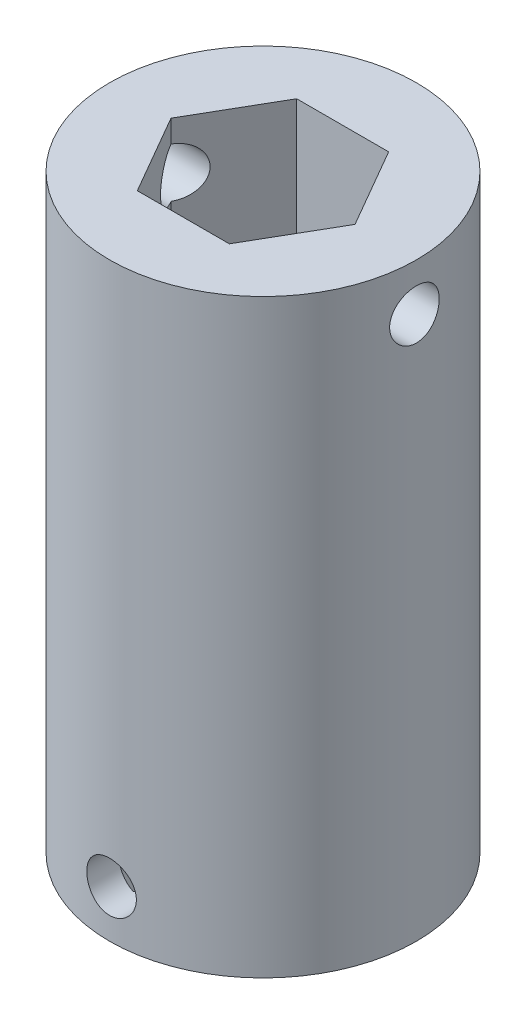
from build123d import *

# Parameters (mm, degrees)
SKETCH1_R               = 13
BOSS_EXTRUDE1_DEPTH     = 30
SKETCH2_R               = 13
BOSS_EXTRUDE2_DEPTH     = 20
CUT_EXTRUDE1_DEPTH      = 23
SKETCH4_R               = 2.1
CUT_EXTRUDE2_DEPTH      = 14
CUT_EXTRUDE2_DEPTH_BACK = 14
SKETCH5_R               = 2.1
CUT_EXTRUDE3_DEPTH      = 14.0000001
CUT_EXTRUDE3_DEPTH_BACK = 14.0000001


with BuildPart() as part:
    # Sketch1 → Boss-Extrude1 (new body)
    with BuildSketch(Plane(origin=(0, 0, 0), x_dir=(1, 0, 0), z_dir=(0, 1, 0))):
        Circle(SKETCH1_R)
        Polygon((7.794228634, 0), (3.897114317, 6.75), (-3.897114317, 6.75), (-7.794228634, 0), (-3.897114317, -6.75), (3.897114317, -6.75), align=None, mode=Mode.SUBTRACT)
    extrude(amount=BOSS_EXTRUDE1_DEPTH)

    # Sketch2 → Boss-Extrude2 (add)
    with BuildSketch(Plane.XZ):
        Circle(SKETCH2_R)
    extrude(amount=BOSS_EXTRUDE2_DEPTH)

    # Sketch3 → Cut-Extrude1 (cut)
    with BuildSketch(Plane.XZ.offset(20)):
        with BuildLine():
            ThreePointArc((-6.243810885, 8.267068745), (-5.854092687, 6.785901876), (-5.214210168, 5.394396961))
            ThreePointArc((-5.214210168, 5.394396961), (-5.398189483, 5.210283731), (-5.575671687, 5.01989955))
            ThreePointArc((-5.575671687, 5.01989955), (-6.988964837, 5.610101244), (-8.483004255, 5.947120212))
            ThreePointArc((-8.483004255, 5.947120212), (-8.868301959, 5.35563445), (-9.212425923, 4.739283555))
            ThreePointArc((-9.212425923, 4.739283555), (-8.21864774, 3.573890707), (-7.038382156, 2.597822718))
            ThreePointArc((-7.038382156, 2.597822718), (-7.124258054, 2.352116797), (-7.201559394, 2.103579935))
            ThreePointArc((-7.201559394, 2.103579935), (-8.730971441, 2.022128371), (-10.223281494, 1.67753256))
            ThreePointArc((-10.223281494, 1.67753256), (-10.313786677, 0.977447894), (-10.356407024, 0.272825133))
            ThreePointArc((-10.356407024, 0.272825133), (-8.955398813, -0.345973348), (-7.468516238, -0.713282174))
            ThreePointArc((-7.468516238, -0.713282174), (-7.439279945, -0.971915715), (-7.401089942, -1.229379485))
            ThreePointArc((-7.401089942, -1.229379485), (-8.743702074, -1.966351826), (-9.938712454, -2.924310989))
            ThreePointArc((-9.938712454, -2.924310989), (-9.716499453, -3.594334206), (-9.449174701, -4.247669652))
            ThreePointArc((-9.449174701, -4.247669652), (-7.918423321, -4.197313138), (-6.419419083, -3.883112783))
            ThreePointArc((-6.419419083, -3.883112783), (-6.280861205, -4.1034484), (-6.134743859, -4.318845221))
            ThreePointArc((-6.134743859, -4.318845221), (-7.024635276, -5.565371928), (-7.685659521, -6.946958883))
            ThreePointArc((-7.685659521, -6.946958883), (-7.194740347, -7.454214334), (-6.670417442, -7.926861368))
            ThreePointArc((-6.670417442, -7.926861368), (-5.313106976, -7.217323584), (-4.09887725, -6.283845283))
            ThreePointArc((-4.09887725, -6.283845283), (-3.878440875, -6.422242804), (-3.653336516, -6.552910693))
            ThreePointArc((-3.653336516, -6.552910693), (-3.91425331, -8.062101865), (-3.910367462, -9.593676371))
            ThreePointArc((-3.910367462, -9.593676371), (-3.247974678, -9.837695893), (-2.570502201, -10.036040974))
            ThreePointArc((-2.570502201, -10.036040974), (-1.655464634, -8.80785458), (-0.966502508, -7.439985158))
            ThreePointArc((-0.966502508, -7.439985158), (-0.707847763, -7.469033257), (-0.448341071, -7.489091836))
            ThreePointArc((-0.448341071, -7.489091836), (-0.028605471, -8.962033652), (0.63942083, -10.340248595))
            ThreePointArc((0.63942083, -10.340248595), (1.34209221, -10.27270113), (2.038532526, -10.157459581))
            ThreePointArc((2.038532526, -10.157459581), (2.330062781, -8.653881955), (2.357299909, -7.122544727))
            ThreePointArc((2.357299909, -7.122544727), (2.60294328, -7.036490072), (2.845453821, -6.941966494))
            ThreePointArc((2.845453821, -6.941966494), (3.862708032, -8.086924763), (5.062563985, -9.03880777))
            ThreePointArc((5.062563985, -9.03880777), (5.666341276, -8.673071921), (6.243810885, -8.267068745))
            ThreePointArc((6.243810885, -8.267068745), (5.854092687, -6.785901876), (5.214210168, -5.394396961))
            ThreePointArc((5.214210168, -5.394396961), (5.398189483, -5.210283731), (5.575671687, -5.01989955))
            ThreePointArc((5.575671687, -5.01989955), (6.988964837, -5.610101244), (8.483004255, -5.947120212))
            ThreePointArc((8.483004255, -5.947120212), (8.868301959, -5.35563445), (9.212425923, -4.739283555))
            ThreePointArc((9.212425923, -4.739283555), (8.21864774, -3.573890707), (7.038382156, -2.597822718))
            ThreePointArc((7.038382156, -2.597822718), (7.124258054, -2.352116797), (7.201559394, -2.103579935))
            ThreePointArc((7.201559394, -2.103579935), (8.730971441, -2.022128371), (10.223281494, -1.67753256))
            ThreePointArc((10.223281494, -1.67753256), (10.313786677, -0.977447894), (10.356407024, -0.272825133))
            ThreePointArc((10.356407024, -0.272825133), (8.955398813, 0.345973348), (7.468516238, 0.713282174))
            ThreePointArc((7.468516238, 0.713282174), (7.439279945, 0.971915715), (7.401089942, 1.229379485))
            ThreePointArc((7.401089942, 1.229379485), (8.743702074, 1.966351826), (9.938712454, 2.924310989))
            ThreePointArc((9.938712454, 2.924310989), (9.716499453, 3.594334206), (9.449174701, 4.247669652))
            ThreePointArc((9.449174701, 4.247669652), (7.918423321, 4.197313138), (6.419419083, 3.883112783))
            ThreePointArc((6.419419083, 3.883112783), (6.280861205, 4.1034484), (6.134743859, 4.318845221))
            ThreePointArc((6.134743859, 4.318845221), (7.024635276, 5.565371928), (7.685659521, 6.946958883))
            ThreePointArc((7.685659521, 6.946958883), (7.194740347, 7.454214334), (6.670417442, 7.926861368))
            ThreePointArc((6.670417442, 7.926861368), (5.313106976, 7.217323584), (4.09887725, 6.283845283))
            ThreePointArc((4.09887725, 6.283845283), (3.878440875, 6.422242804), (3.653336516, 6.552910693))
            ThreePointArc((3.653336516, 6.552910693), (3.91425331, 8.062101865), (3.910367462, 9.593676371))
            ThreePointArc((3.910367462, 9.593676371), (3.247974678, 9.837695893), (2.570502201, 10.036040974))
            ThreePointArc((2.570502201, 10.036040974), (1.655464634, 8.80785458), (0.966502508, 7.439985158))
            ThreePointArc((0.966502508, 7.439985158), (0.707847763, 7.469033257), (0.448341071, 7.489091836))
            ThreePointArc((0.448341071, 7.489091836), (0.028605471, 8.962033652), (-0.63942083, 10.340248595))
            ThreePointArc((-0.63942083, 10.340248595), (-1.34209221, 10.27270113), (-2.038532526, 10.157459581))
            ThreePointArc((-2.038532526, 10.157459581), (-2.330062781, 8.653881955), (-2.357299909, 7.122544727))
            ThreePointArc((-2.357299909, 7.122544727), (-2.60294328, 7.036490072), (-2.845453821, 6.941966494))
            ThreePointArc((-2.845453821, 6.941966494), (-3.862708032, 8.086924763), (-5.062563985, 9.03880777))
            ThreePointArc((-5.062563985, 9.03880777), (-5.666341276, 8.673071921), (-6.243810885, 8.267068745))
        make_face()
    extrude(amount=-CUT_EXTRUDE1_DEPTH, mode=Mode.SUBTRACT)

    # Sketch4 → Cut-Extrude2 (cut, two sides)
    with BuildSketch(Plane.XY) as cut_extrude2_sk:
        with Locations((0, -16)):
            Circle(SKETCH4_R)
    extrude(amount=CUT_EXTRUDE2_DEPTH, mode=Mode.SUBTRACT)
    extrude(cut_extrude2_sk.sketch, amount=-CUT_EXTRUDE2_DEPTH_BACK, mode=Mode.SUBTRACT)

    # Sketch5 → Cut-Extrude3 (cut, two sides)
    with BuildSketch(Plane(origin=(0, 0, 0), x_dir=(0, 0, -1), z_dir=(1, 0, 0))) as cut_extrude3_sk:
        with Locations((0, 26)):
            Circle(SKETCH5_R)
    extrude(amount=CUT_EXTRUDE3_DEPTH, mode=Mode.SUBTRACT)
    extrude(cut_extrude3_sk.sketch, amount=-CUT_EXTRUDE3_DEPTH_BACK, mode=Mode.SUBTRACT)


solid = part.part
